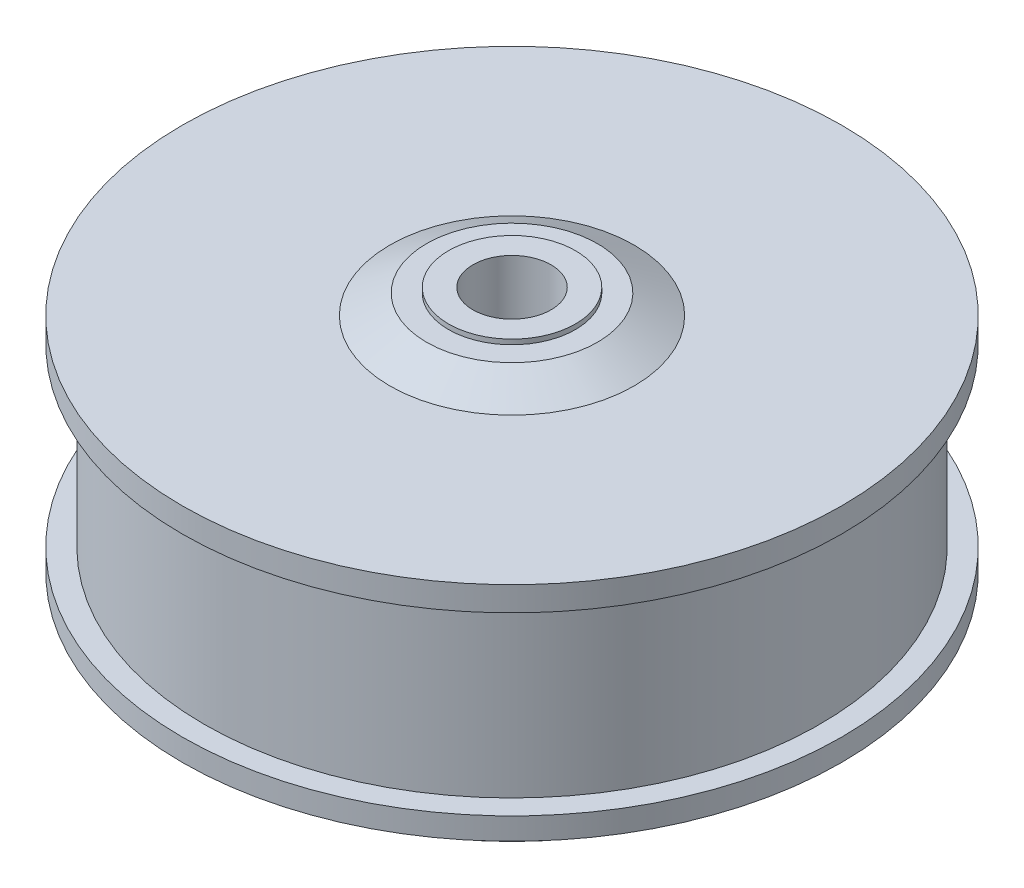
from build123d import *

# Parameters (mm, degrees)
SKETCH2_R          = 2
CUT_EXTRUDE1_DEPTH = 10


with BuildPart() as part:
    # Sketch1 → Revolve1 (revolve)
    with BuildSketch(Plane.XY):
        Polygon((17.5, 60.5), (13, 60.5), (13, 61.5), (8, 61.5), (8, 20.5), (0, 20.5), (0, 0), (52, 0), (61.5, 11), (67.5, 11), (67.5, 15.5), (63, 15.5), (63, 51.5), (67.5, 51.5), (67.5, 56.5), (25, 56.5), align=None)
    revolve(axis=Axis((0, 20.5, 0), (0, -1, 0)))

    # Sketch2 → Cut-Extrude1 (cut)
    with BuildSketch(Plane.XZ):
        with Locations((0, 27.5)):
            Circle(SKETCH2_R)
        with Locations((19.445436483, 19.445436483)):
            Circle(SKETCH2_R)
        with Locations((27.5, 0)):
            Circle(SKETCH2_R)
        with Locations((19.445436483, -19.445436483)):
            Circle(SKETCH2_R)
        with Locations((0, -27.5)):
            Circle(SKETCH2_R)
        with Locations((-19.445436483, -19.445436483)):
            Circle(SKETCH2_R)
        with Locations((-27.5, 0)):
            Circle(SKETCH2_R)
        with Locations((-19.445436483, 19.445436483)):
            Circle(SKETCH2_R)
    extrude(amount=-CUT_EXTRUDE1_DEPTH, mode=Mode.SUBTRACT)


solid = part.part
